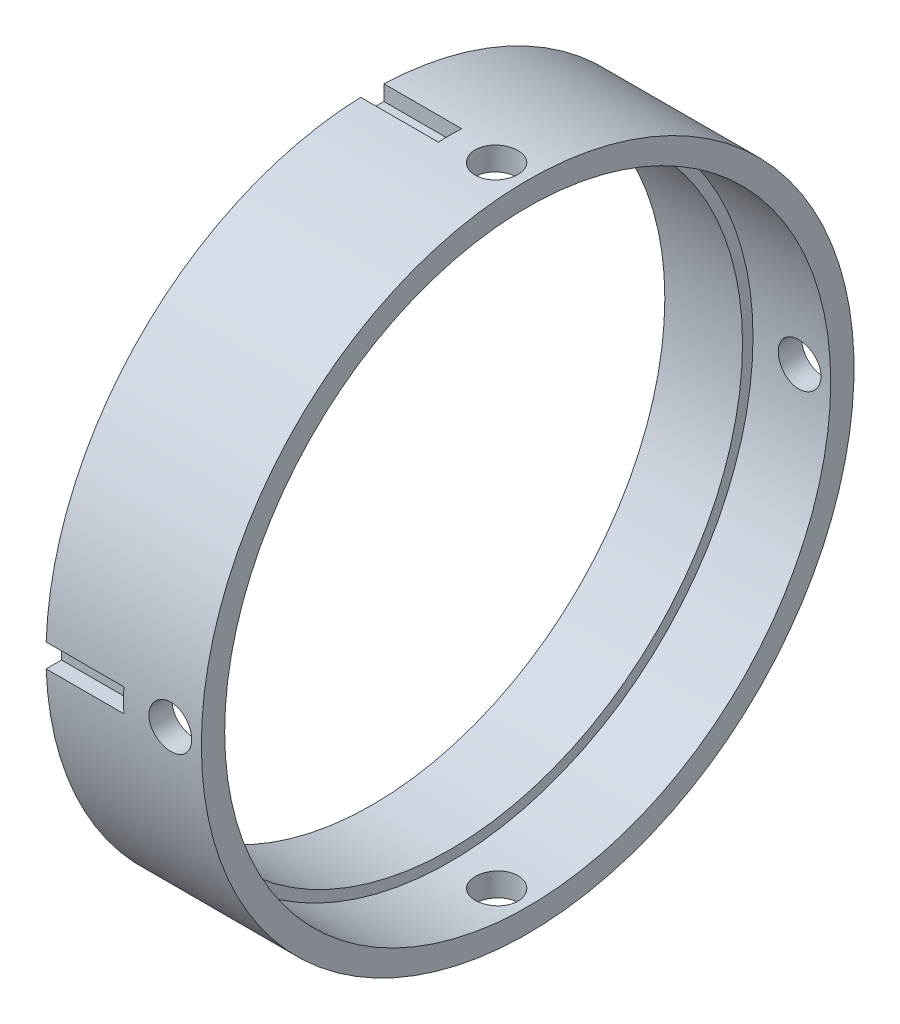
from build123d import *

# Parameters (mm, degrees)
D_GAGEMENT_M51_D             = 5.5
R_P_TITION_CIRCULAIRE1_COUNT = 2
R_P_TITION_CIRCULAIRE1_ANGLE = 90
ESQUISSE5_W                  = 3
ESQUISSE5_H                  = 15
ENL_V_MAT_EXTRU_1_DEPTH      = 10
R_P_TITION_CIRCULAIRE2_COUNT = 4


with BuildPart() as part:
    # Esquisse1 → Révolution1 (revolve)
    with BuildSketch(Plane.XY):
        Polygon((0, 37.65), (10, 37.65), (10, 39), (20, 39), (20, 42), (0, 42), align=None)
    revolve(axis=Axis((0, 0, 0), (1, 0, 0)))

    # Dégagement M51 (through all)
    with Locations(Plane(origin=(16, 42, 0), x_dir=(0, 0, 1), z_dir=(0, 1, 0))):
        with Locations((0, 0)):
            d_gagement_m51 = Hole(D_GAGEMENT_M51_D / 2)

    # Répétition circulaire1: Dégagement M51 ×2 about axis
    r_p_tition_circulaire1_axis = Axis((20, 0, 0), (-1, 0, 0))
    for i in range(1, R_P_TITION_CIRCULAIRE1_COUNT):
        add(d_gagement_m51.rotate(r_p_tition_circulaire1_axis, i * R_P_TITION_CIRCULAIRE1_ANGLE / (R_P_TITION_CIRCULAIRE1_COUNT - 1)), mode=Mode.SUBTRACT)

    # Esquisse5 → Enlèv. mat.-Extru.1 (cut)
    with BuildSketch(Plane.ZY):
        with Locations((0, 47.5)):
            Rectangle(ESQUISSE5_W, ESQUISSE5_H)
    enl_v_mat_extru_1 = extrude(amount=-ENL_V_MAT_EXTRU_1_DEPTH, mode=Mode.SUBTRACT)

    # Répétition circulaire2: Enlèv. mat.-Extru.1 ×4 about axis
    r_p_tition_circulaire2_axis = Axis((0, 0, 0), (1, 0, 0))
    for i in range(1, R_P_TITION_CIRCULAIRE2_COUNT):
        add(enl_v_mat_extru_1.rotate(r_p_tition_circulaire2_axis, i * 360 / R_P_TITION_CIRCULAIRE2_COUNT), mode=Mode.SUBTRACT)


solid = part.part
